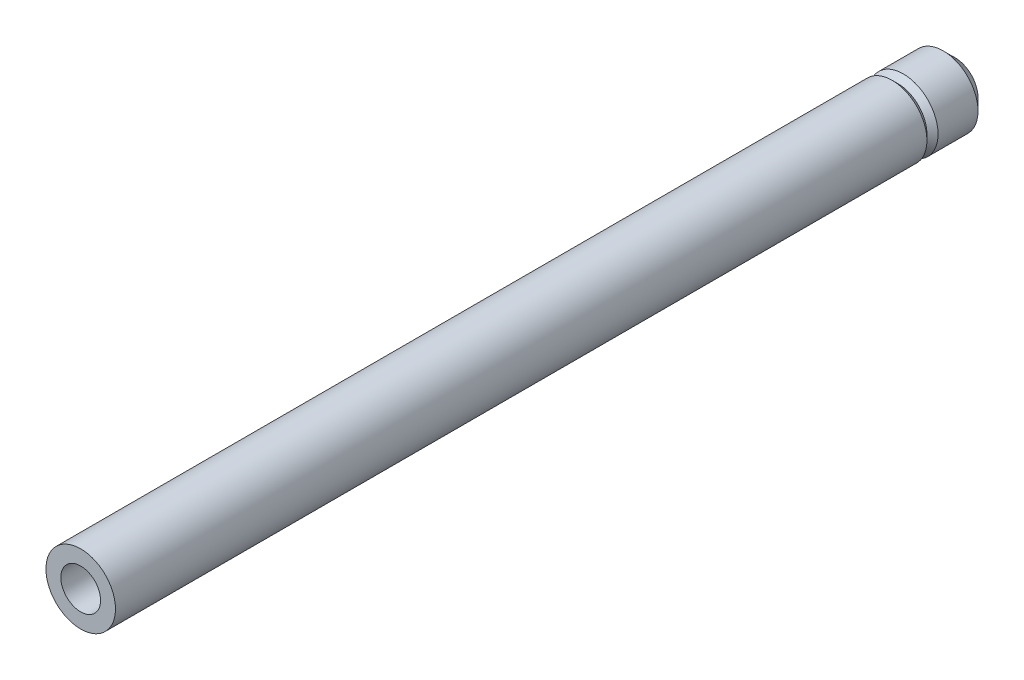
from build123d import *


with BuildPart() as part:
    # Sketch1 → Revolve1 (revolve)
    with BuildSketch(Plane(origin=(0, 0, 0), x_dir=(0, 0, -1), z_dir=(1, 0, 0)), mode=Mode.PRIVATE) as revolve1_sk:
        Polygon((-184.976381406, 6.35), (91.883618594, 6.35), (91.883618594, 6.858), (94.423618594, 6.858), (94.423618594, 7.366), (90.677118594, 11.1125), (77.913618594, 11.1125), (76.135618594, 9.3345), (74.357618594, 11.1125), (-184.976381406, 11.1125), align=None)
    revolve(revolve1_sk.sketch.rotate(Axis((0, 0, 90.130122331), (0, 0, -1)), 90), axis=Axis((0, 0, 90.130122331), (0, 0, -1)))  # turned: the seam where the file's is


solid = part.part
